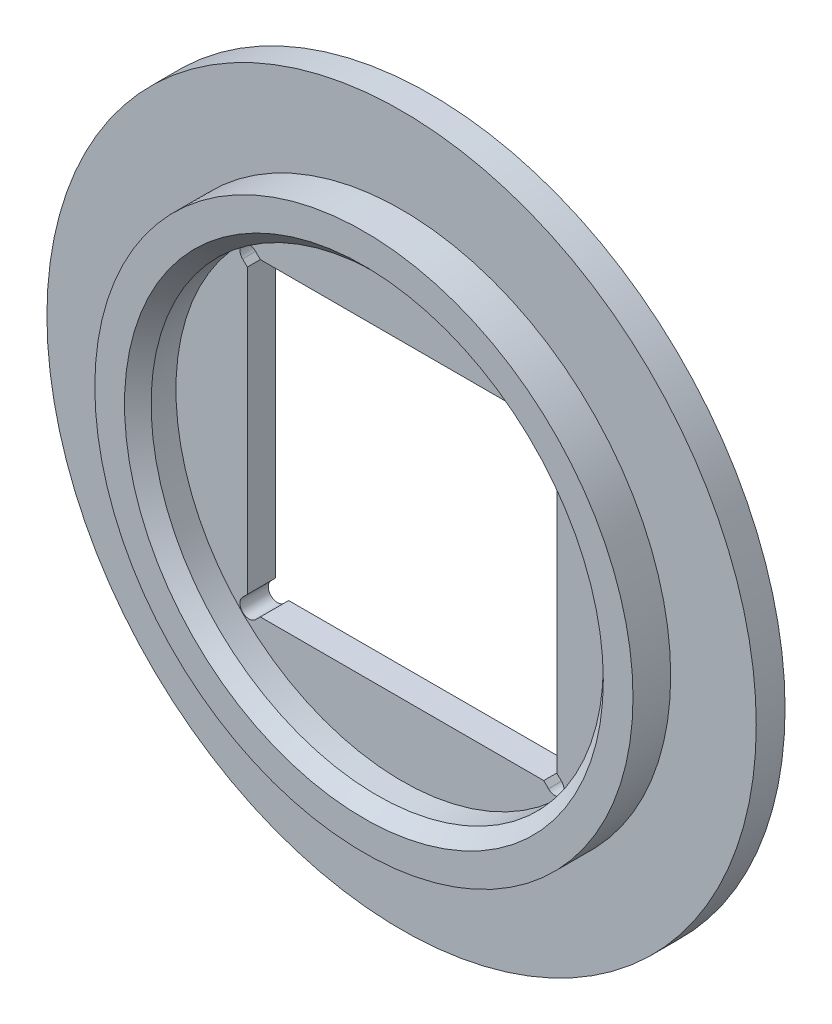
from build123d import *

# Parameters (mm, degrees)
SKETCH_1_R          = 8
EXTRUDE_1_DEPTH     = 0.65
EXTRUDE_START       = 0.65
SKETCH_2_R          = 6.07
SKETCH_2_R_2        = 5.1
EXTRUDE_2_DEPTH     = 0.85
CUT_EXTRUDE_START   = 0.65
SKETCH_3_R          = 5.1
CUT_EXTRUDE_1_DEPTH = 0.01
CUT_EXTRUDE_2_DEPTH = 0.64
CHAMFER_1_SIZE      = 0.3
SKETCH_6_R          = 0.207363545
CUT_EXTRUDE_3_DEPTH = 0.64
CUT_EXTRUDE_4_DEPTH = 0.64


with BuildPart() as part:
    # 草图1 → 凸台-拉伸1 (new body)
    with BuildSketch(Plane.XY):
        Circle(SKETCH_1_R)
    extrude(amount=EXTRUDE_1_DEPTH)

    # 草图2 → 凸台-拉伸2 (add)
    with BuildSketch(Plane.XY.offset(EXTRUDE_START)):
        Circle(SKETCH_2_R)
        Circle(SKETCH_2_R_2, mode=Mode.SUBTRACT)
    extrude(amount=EXTRUDE_2_DEPTH)

    # 草图3 → 切除-拉伸1 (cut)
    with BuildSketch(Plane.XY.offset(CUT_EXTRUDE_START)):
        Circle(SKETCH_3_R)
    extrude(amount=-CUT_EXTRUDE_1_DEPTH, mode=Mode.SUBTRACT)

    # 草图4 → 切除-拉伸2 (cut)
    with BuildSketch(Plane.XY):
        Polygon((-3.49, 0), (-3.49, 3.49), (3.49, 3.49), (3.49, -3.49), (-3.49, -3.49), align=None)
    extrude(amount=CUT_EXTRUDE_2_DEPTH, mode=Mode.SUBTRACT)

    # 倒角1
    chamfer_1_edges = [part.edges().sort_by_distance(p)[0] for p in [
        (-5.1, 0, 1.5),
    ]]
    chamfer(chamfer_1_edges, length=CHAMFER_1_SIZE)

    # 草图6 → 切除-拉伸3 (cut)
    with BuildSketch(Plane.XY):
        with Locations((-3.45, 3.45)):
            Circle(SKETCH_6_R)
        with Locations((3.45, 3.45)):
            Circle(SKETCH_6_R)
        with Locations((3.45, -3.45)):
            Circle(SKETCH_6_R)
        with Locations((-3.45, -3.45)):
            Circle(SKETCH_6_R)
    extrude(amount=CUT_EXTRUDE_3_DEPTH, mode=Mode.SUBTRACT)

    # 草图7 → 切除-拉伸4 (cut)
    with BuildSketch(Plane.XY):
        Polygon((-3.45, 3.45), (-3.596628169, 3.303371831), (-3.126421006, 2.833164668), (-2.833164668, 3.126421006), (-3.303371831, 3.596628169), align=None)
        Polygon((2.833164668, 3.126421006), (3.126421006, 2.833164668), (3.596628169, 3.303371831), (3.45, 3.45), (3.303371831, 3.596628169), align=None)
        Polygon((3.45, -3.45), (3.596628169, -3.303371831), (3.126421006, -2.833164668), (2.833164668, -3.126421006), (3.303371831, -3.596628169), align=None)
        Polygon((-2.833164668, -3.126421006), (-3.126421006, -2.833164668), (-3.596628169, -3.303371831), (-3.45, -3.45), (-3.303371831, -3.596628169), align=None)
    extrude(amount=CUT_EXTRUDE_4_DEPTH, mode=Mode.SUBTRACT)


solid = part.part
